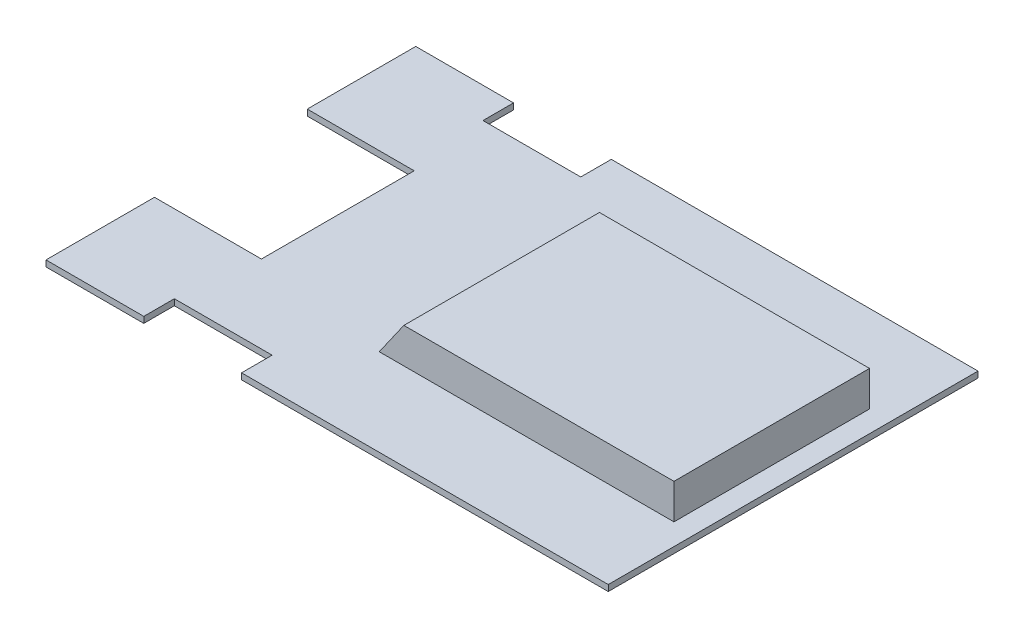
from build123d import *

# Parameters (mm, degrees)
SKICA1_W                 = 184
SKICA1_H                 = 121
P_IDAT_VYSUNUT_M1_DEPTH  = 2
SKICA2_W                 = 32
SKICA2_H                 = 10
ODEBRAT_VYSUNUT_M1_DEPTH = 3
SKICA3_W                 = 35
SKICA3_H                 = 50
ODEBRAT_VYSUNUT_M2_DEPTH = 10
SKICA5_W                 = 90
SKICA5_H                 = 60
ODEBRAT_VYSUNUT_M3_DEPTH = 10
SKICA6_W                 = 94
SKICA6_H                 = 64
SKICA6_W_2               = 90
SKICA6_H_2               = 60
P_IDAT_VYSUNUT_M2_DEPTH  = 10
ODEBRAT_VYSUNUT_M4_DEPTH = 93.5
P_IDAT_VYSUNUT_M3_DEPTH  = 64
SKICA9_W                 = 89.439473795
SKICA9_H                 = 64
P_IDAT_VYSUNUT_M4_DEPTH  = 1.5
ODEBRAT_VYSUNUT_M5_DEPTH = 93.5
P_IDAT_VYSUNUT_M5_DEPTH  = 0.75
LINPOLE1_COUNT           = 2
LINPOLE1_PITCH           = 15
LINPOLE1_COL_COUNT       = 2
LINPOLE1_COL_PITCH       = 15
SKICA12_W                = 1
SKICA12_H                = 8
ODEBRAT_VYSUNUT_M6_DEPTH = 31.5


with BuildPart() as part:
    # Skica1 → Přidat vysunutím1 (new body)
    with BuildSketch(Plane(origin=(0, 0, 0), x_dir=(1, 0, 0), z_dir=(0, 1, 0))):
        Rectangle(SKICA1_W, SKICA1_H)
    extrude(amount=P_IDAT_VYSUNUT_M1_DEPTH)

    # Skica2 → Odebrat vysunutím1 (cut)
    with BuildSketch(Plane(origin=(0, 2, 0), x_dir=(1, 0, 0), z_dir=(0, 1, 0))):
        with Locations((-44, 55.5)):
            Rectangle(SKICA2_W, SKICA2_H)
        with Locations((-44, -55.5)):
            Rectangle(SKICA2_W, SKICA2_H)
    extrude(amount=-ODEBRAT_VYSUNUT_M1_DEPTH, mode=Mode.SUBTRACT)

    # Skica3 → Odebrat vysunutím2 (cut)
    with BuildSketch(Plane(origin=(0, 2, 0), x_dir=(1, 0, 0), z_dir=(0, 1, 0))):
        with Locations((-74.5, 0)):
            Rectangle(SKICA3_W, SKICA3_H)
    extrude(amount=-ODEBRAT_VYSUNUT_M2_DEPTH, mode=Mode.SUBTRACT)

    # Skica5 → Odebrat vysunutím3 (cut)
    with BuildSketch(Plane(origin=(0, 2, 0), x_dir=(1, 0, 0), z_dir=(0, 1, 0))):
        with Locations((38, 0)):
            Rectangle(SKICA5_W, SKICA5_H)
    extrude(amount=-ODEBRAT_VYSUNUT_M3_DEPTH, mode=Mode.SUBTRACT)

    # Skica6 → Přidat vysunutím2 (add)
    with BuildSketch(Plane(origin=(0, 2, 0), x_dir=(1, 0, 0), z_dir=(0, 1, 0))):
        with Locations((38, 0)):
            Rectangle(SKICA6_W, SKICA6_H)
        with Locations((38, 0)):
            Rectangle(SKICA6_W_2, SKICA6_H_2, mode=Mode.SUBTRACT)
    extrude(amount=P_IDAT_VYSUNUT_M2_DEPTH)

    # Skica7 → Odebrat vysunutím4 (cut, through all)
    with BuildSketch(Plane.XY.offset(32)):
        Polygon((-9, 2), (-1.997924618, 12), (-9, 12), align=None)
    extrude(amount=-ODEBRAT_VYSUNUT_M4_DEPTH, mode=Mode.SUBTRACT)

    # Skica8 → Přidat vysunutím3 (add)
    with BuildSketch(Plane.XY.offset(32)):
        Polygon((-1.997924618, 12), (-4.439473795, 12), (-11.441549178, 2), (-9, 2), align=None)
    extrude(amount=-P_IDAT_VYSUNUT_M3_DEPTH)

    # Skica9 → Přidat vysunutím4 (add)
    with BuildSketch(Plane(origin=(0, 12, 0), x_dir=(1, 0, 0), z_dir=(0, 1, 0))):
        with Locations((40.280263103, 0)):
            Rectangle(SKICA9_W, SKICA9_H)
    extrude(amount=P_IDAT_VYSUNUT_M4_DEPTH)

    # Skica10 → Odebrat vysunutím5 (cut, through all)
    with BuildSketch(Plane.XY.offset(32)):
        Polygon((-4.439473795, 12), (-3.389162488, 13.5), (-4.439473795, 13.5), align=None)
    extrude(amount=-ODEBRAT_VYSUNUT_M5_DEPTH, mode=Mode.SUBTRACT)

    # Skica11 → Přidat vysunutím5 (add, symmetric)
    with BuildSketch(Plane.XY):
        Polygon((83, 12), (-1.997924618, 12), (-7, 4.856296013), (-7, 0), (83, 0), align=None)
    p_idat_vysunut_m5 = extrude(amount=P_IDAT_VYSUNUT_M5_DEPTH, both=True)

    # LinPole1: Přidat vysunutím5 ×2
    with Locations(*[(0, 0, i * LINPOLE1_PITCH) for i in range(1, LINPOLE1_COUNT)]):
        add(p_idat_vysunut_m5)

    # LinPole1 col: Přidat vysunutím5 ×2
    with Locations(*[(0, 0, -i * LINPOLE1_COL_PITCH) for i in range(1, LINPOLE1_COL_COUNT)]):
        add(p_idat_vysunut_m5)

    # Skica12 → Odebrat vysunutím6 (cut)
    with BuildSketch(Plane.XY.offset(15.75)):
        with Locations((8.5, 4)):
            Rectangle(SKICA12_W, SKICA12_H)
        with Locations((34.5, 4)):
            Rectangle(SKICA12_W, SKICA12_H)
        with Locations((60.5, 4)):
            Rectangle(SKICA12_W, SKICA12_H)
    extrude(amount=-ODEBRAT_VYSUNUT_M6_DEPTH, mode=Mode.SUBTRACT)


solid = part.part
